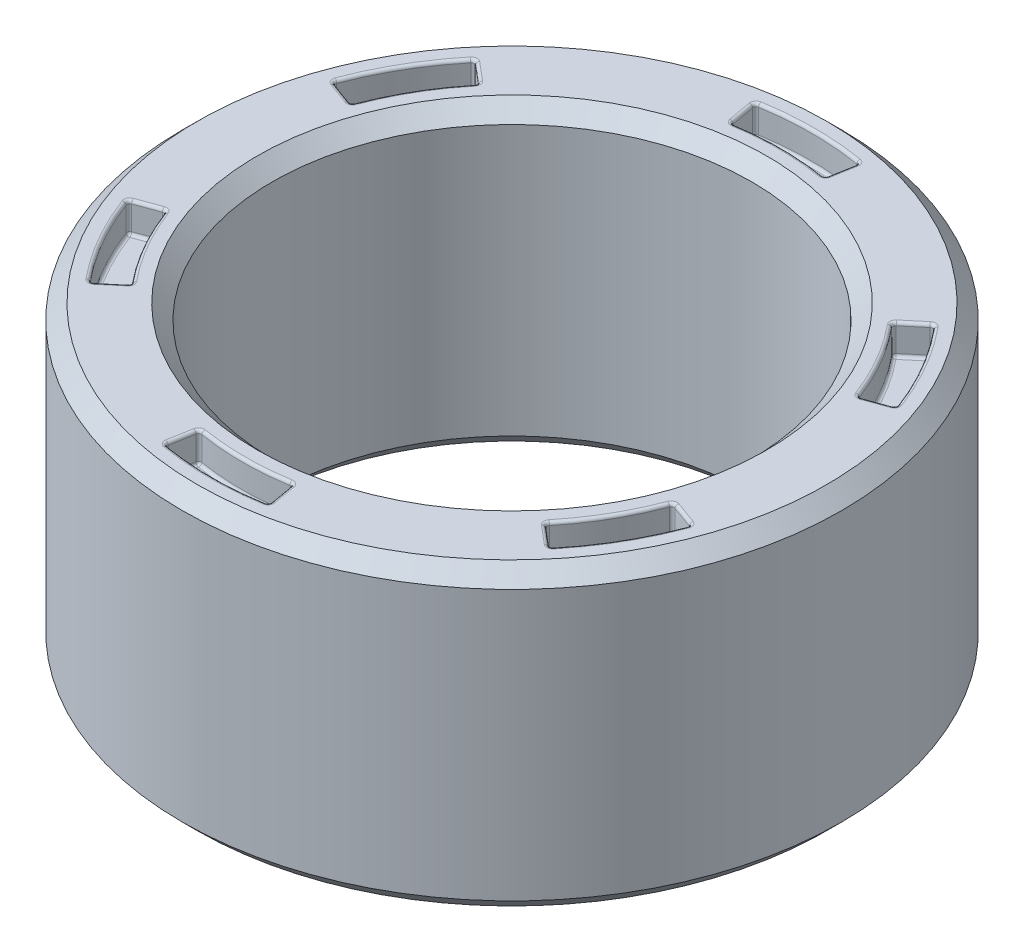
from build123d import *

# Parameters (mm, degrees)
SKETCH1_R                = 11
SKETCH1_R_2              = 8
BOSS_EXTRUDE1_DEPTH      = 10
CHAMFER1_SIZE            = 0.5
CUT_EXTRUDE1_DEPTH       = 1
FILLET1_R                = 0.1
CIRPATTERN1_COUNT        = 6
FILLET1_OF_CIRPATTERN1_R = 0.1


with BuildPart() as part:
    # Sketch1 → Boss-Extrude1 (new body)
    with BuildSketch(Plane(origin=(0, 0, 0), x_dir=(1, 0, 0), z_dir=(0, 1, 0))):
        Circle(SKETCH1_R)
        Circle(SKETCH1_R_2, mode=Mode.SUBTRACT)
    extrude(amount=BOSS_EXTRUDE1_DEPTH)

    # Chamfer1
    chamfer1_edges = [part.edges().sort_by_distance(p)[0] for p in [
        (-11, 0, 0),
        (-11, 10, 0),
        (-8, 0, 0),
        (-8, 10, 0),
    ]]
    chamfer(chamfer1_edges, length=CHAMFER1_SIZE)

    # Sketch2 → Cut-Extrude1 (cut)
    with BuildSketch(Plane(origin=(0, 10, 0), x_dir=(1, 0, 0), z_dir=(0, 1, 0))):
        with BuildLine():
            Line((-1.562833599, 8.863269777), (-1.736481777, 9.84807753))
            ThreePointArc((-1.736481777, 9.84807753), (0, 10), (1.736481777, 9.84807753))
            Line((1.736481777, 9.84807753), (1.562833599, 8.863269777))
            ThreePointArc((1.562833599, 8.863269777), (0, 9), (-1.562833599, 8.863269777))
        make_face()
    cut_extrude1 = extrude(amount=-CUT_EXTRUDE1_DEPTH, mode=Mode.SUBTRACT)

    # Fillet1
    fillet1_edges = [part.edges().sort_by_distance(p)[0] for p in [
        (0, 9, -9),
        (1.562833599, 9.5, -8.863269777),
        (-1.649657688, 9, -9.355673654),
        (-1.562833599, 9.5, -8.863269777),
        (0, 9, -10),
        (-1.736481777, 9.5, -9.84807753),
        (1.649657688, 9, -9.355673654),
        (1.736481777, 9.5, -9.84807753),
        (0, 10, -9),
        (1.649657688, 10, -9.355673654),
        (0, 10, -10),
        (-1.649657688, 10, -9.355673654),
    ]]
    fillet(fillet1_edges, radius=FILLET1_R)

    # CirPattern1: Cut-Extrude1 ×6 about axis
    cirpattern1_axis = Axis((0, 0, 0), (0, 1, 0))
    for i in range(1, CIRPATTERN1_COUNT):
        add(cut_extrude1.rotate(cirpattern1_axis, i * 360 / CIRPATTERN1_COUNT), mode=Mode.SUBTRACT)

    # Fillet1 of CirPattern1
    fillet1_of_cirpattern1_edges = [part.edges().sort_by_distance(p)[0] for p in [
        (-7.794228634, 9, -4.5),
        (-6.894399988, 9.5, -5.785088487),
        (-8.927079897, 9, -3.249191362),
        (-8.457233587, 9.5, -3.07818129),
        (-8.660254038, 9, -5),
        (-9.396926208, 9.5, -3.420201433),
        (-7.27742221, 9, -6.106482292),
        (-7.660444431, 9.5, -6.427876097),
        (-7.794228634, 10, -4.5),
        (-7.27742221, 10, -6.106482292),
        (-8.660254038, 10, -5),
        (-8.927079897, 10, -3.249191362),
        (-7.794228634, 9, 4.5),
        (-8.457233587, 9.5, 3.07818129),
        (-7.27742221, 9, 6.106482292),
        (-6.894399988, 9.5, 5.785088487),
        (-8.660254038, 9, 5),
        (-7.660444431, 9.5, 6.427876097),
        (-8.927079897, 9, 3.249191362),
        (-9.396926208, 9.5, 3.420201433),
        (-7.794228634, 10, 4.5),
        (-8.927079897, 10, 3.249191362),
        (-8.660254038, 10, 5),
        (-7.27742221, 10, 6.106482292),
        (0, 9, 9),
        (-1.562833599, 9.5, 8.863269777),
        (1.649657688, 9, 9.355673654),
        (1.562833599, 9.5, 8.863269777),
        (0, 9, 10),
        (1.736481777, 9.5, 9.84807753),
        (-1.649657688, 9, 9.355673654),
        (-1.736481777, 9.5, 9.84807753),
        (0, 10, 9),
        (-1.649657688, 10, 9.355673654),
        (0, 10, 10),
        (1.649657688, 10, 9.355673654),
        (7.794228634, 9, 4.5),
        (6.894399988, 9.5, 5.785088487),
        (8.927079897, 9, 3.249191362),
        (8.457233587, 9.5, 3.07818129),
        (8.660254038, 9, 5),
        (9.396926208, 9.5, 3.420201433),
        (7.27742221, 9, 6.106482292),
        (7.660444431, 9.5, 6.427876097),
        (7.794228634, 10, 4.5),
        (7.27742221, 10, 6.106482292),
        (8.660254038, 10, 5),
        (8.927079897, 10, 3.249191362),
        (7.794228634, 9, -4.5),
        (8.457233587, 9.5, -3.07818129),
        (7.27742221, 9, -6.106482292),
        (6.894399988, 9.5, -5.785088487),
        (8.660254038, 9, -5),
        (7.660444431, 9.5, -6.427876097),
        (8.927079897, 9, -3.249191362),
        (9.396926208, 9.5, -3.420201433),
        (7.794228634, 10, -4.5),
        (8.927079897, 10, -3.249191362),
        (8.660254038, 10, -5),
        (7.27742221, 10, -6.106482292),
    ]]
    fillet(fillet1_of_cirpattern1_edges, radius=FILLET1_OF_CIRPATTERN1_R)


solid = part.part
